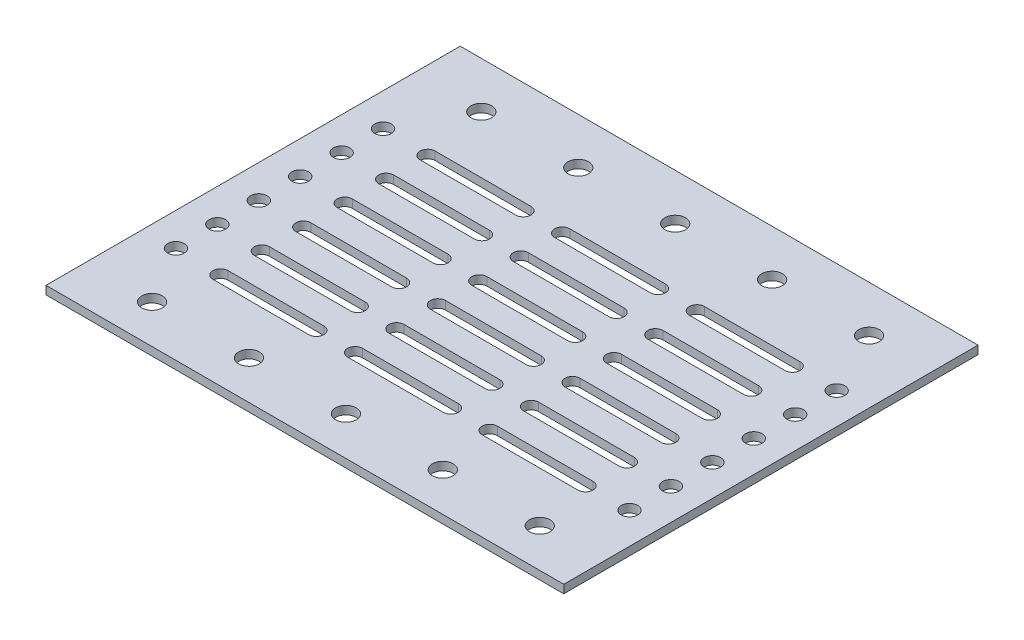
from build123d import *

# Parameters (mm, degrees)
SKETCH1_W            = 125
SKETCH1_H            = 100
BOSS_EXTRUDE1_DEPTH  = 2
CUT_EXTRUDE1_DEPTH   = 3
LPATTERN1_COUNT      = 6
LPATTERN1_PITCH      = 10
LPATTERN1_COUNT_DIR2 = 3
LPATTERN1_PITCH_DIR2 = 32.5
SKETCH3_R            = 2
CUT_EXTRUDE2_DEPTH   = 3
LPATTERN2_COUNT      = 6
LPATTERN2_PITCH      = 10
LPATTERN2_COUNT_DIR2 = 2
LPATTERN2_PITCH_DIR2 = 109.5
SKETCH4_R            = 2.5
CUT_EXTRUDE3_DEPTH   = 20
LPATTERN3_COUNT      = 5
LPATTERN3_PITCH      = 23.4
LPATTERN3_COUNT_DIR2 = 3
LPATTERN3_PITCH_DIR2 = 79.5


with BuildPart() as part:
    # Sketch1 → Boss-Extrude1 (new body)
    with BuildSketch(Plane(origin=(0, 0, 0), x_dir=(1, 0, 0), z_dir=(0, 1, 0))):
        Rectangle(SKETCH1_W, SKETCH1_H)
    extrude(amount=BOSS_EXTRUDE1_DEPTH)

    # Sketch2 → Cut-Extrude1 (cut, through all)
    with BuildSketch(Plane(origin=(0, 2, 0), x_dir=(1, 0, 0), z_dir=(0, 1, 0))):
        with BuildLine():
            Line((-43.604271847, 25.047104991), (-20.48386724, 25.047104991))
            ThreePointArc((-20.48386724, 25.047104991), (-18.658572139, 23.22180989), (-20.48386724, 21.39651479))
            Line((-20.48386724, 21.39651479), (-43.604271847, 21.39651479))
            ThreePointArc((-43.604271847, 21.39651479), (-45.429566947, 23.22180989), (-43.604271847, 25.047104991))
        make_face()
    cut_extrude1 = extrude(amount=-CUT_EXTRUDE1_DEPTH, mode=Mode.SUBTRACT)

    # LPattern1: Cut-Extrude1 6 × 3
    with Locations(*[(j * LPATTERN1_PITCH_DIR2, 0, i * LPATTERN1_PITCH) for i in range(LPATTERN1_COUNT) for j in range(LPATTERN1_COUNT_DIR2) if (i, j) != (0, 0)]):
        add(cut_extrude1, mode=Mode.SUBTRACT)

    # Sketch3 → Cut-Extrude2 (cut, through all)
    with BuildSketch(Plane(origin=(0, 2, 0), x_dir=(1, 0, 0), z_dir=(0, 1, 0))):
        with Locations((-54.55604245, 23.424620457)):
            Circle(SKETCH3_R)
    cut_extrude2 = extrude(amount=-CUT_EXTRUDE2_DEPTH, mode=Mode.SUBTRACT)

    # LPattern2: Cut-Extrude2 6 × 2
    with Locations(*[(j * LPATTERN2_PITCH_DIR2, 0, i * LPATTERN2_PITCH) for i in range(LPATTERN2_COUNT) for j in range(LPATTERN2_COUNT_DIR2) if (i, j) != (0, 0)]):
        add(cut_extrude2, mode=Mode.SUBTRACT)

    # Sketch4 → Cut-Extrude3 (cut)
    with BuildSketch(Plane(origin=(0, 2, 0), x_dir=(1, 0, 0), z_dir=(0, 1, 0))):
        with Locations((-46.240809214, 38.838223529)):
            Circle(SKETCH4_R)
    cut_extrude3 = extrude(amount=-CUT_EXTRUDE3_DEPTH, mode=Mode.SUBTRACT)

    # LPattern3: Cut-Extrude3 5 × 3
    with Locations(*[(i * LPATTERN3_PITCH, 0, j * LPATTERN3_PITCH_DIR2) for i in range(LPATTERN3_COUNT) for j in range(LPATTERN3_COUNT_DIR2) if (i, j) != (0, 0)]):
        add(cut_extrude3, mode=Mode.SUBTRACT)


solid = part.part
